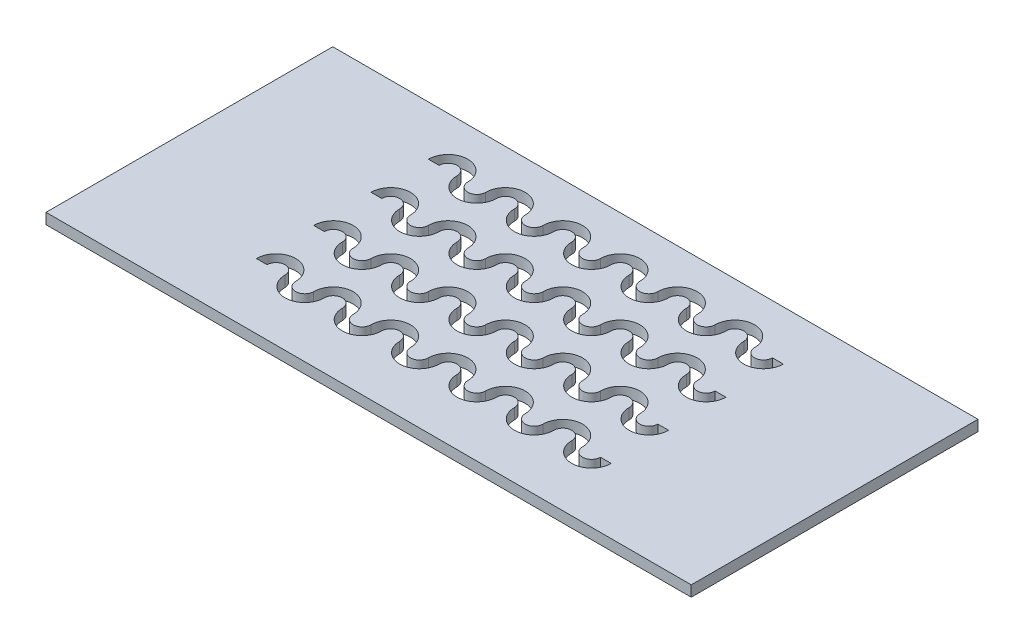
from build123d import *

# Parameters (mm, degrees)
SKETCH1_W               = 180
SKETCH1_H               = 80
BOSS_EXTRUDE1_DEPTH     = 3
CUT_EXTRUDE_THIN1_DEPTH = 5


with BuildPart() as part:
    # Sketch1 → Boss-Extrude1 (new body)
    with BuildSketch(Plane(origin=(0, 0, 0), x_dir=(1, 0, 0), z_dir=(0, 1, 0))):
        with Locations((90, 40)):
            Rectangle(SKETCH1_W, SKETCH1_H)
    extrude(amount=BOSS_EXTRUDE1_DEPTH)

    # Sketch1_3 → Cut-Extrude-Thin1 (cut, symmetric)
    with BuildSketch(Plane(origin=(0, 0, 0), x_dir=(1, 0, 0), z_dir=(0, 1, 0))):
        with BuildLine():
            ThreePointArc((136.5, 66.174335789), (134, 63.674335789), (131.5, 66.174335789))
            ThreePointArc((131.5, 66.174335789), (126, 71.674335789), (120.5, 66.174335789))
            ThreePointArc((120.5, 66.174335789), (118, 63.674335789), (115.5, 66.174335789))
            ThreePointArc((115.5, 66.174335789), (110, 71.674335789), (104.5, 66.174335789))
            ThreePointArc((104.5, 66.174335789), (102, 63.674335789), (99.5, 66.174335789))
            ThreePointArc((99.5, 66.174335789), (94, 71.674335789), (88.5, 66.174335789))
            ThreePointArc((88.5, 66.174335789), (86, 63.674335789), (83.5, 66.174335789))
            ThreePointArc((83.5, 66.174335789), (78, 71.674335789), (72.5, 66.174335789))
            ThreePointArc((72.5, 66.174335789), (70, 63.674335789), (67.5, 66.174335789))
            ThreePointArc((67.5, 66.174335789), (62, 71.674335789), (56.5, 66.174335789))
            ThreePointArc((56.5, 66.174335789), (54, 63.674335789), (51.5, 66.174335789))
            ThreePointArc((51.5, 66.174335789), (46, 71.674335789), (40.5, 66.174335789))
            Line((40.5, 66.174335789), (43.5, 66.174335789))
            ThreePointArc((43.5, 66.174335789), (46, 68.674335789), (48.5, 66.174335789))
            ThreePointArc((48.5, 66.174335789), (54, 60.674335789), (59.5, 66.174335789))
            ThreePointArc((59.5, 66.174335789), (62, 68.674335789), (64.5, 66.174335789))
            ThreePointArc((64.5, 66.174335789), (70, 60.674335789), (75.5, 66.174335789))
            ThreePointArc((75.5, 66.174335789), (78, 68.674335789), (80.5, 66.174335789))
            ThreePointArc((80.5, 66.174335789), (86, 60.674335789), (91.5, 66.174335789))
            ThreePointArc((91.5, 66.174335789), (94, 68.674335789), (96.5, 66.174335789))
            ThreePointArc((96.5, 66.174335789), (102, 60.674335789), (107.5, 66.174335789))
            ThreePointArc((107.5, 66.174335789), (110, 68.674335789), (112.5, 66.174335789))
            ThreePointArc((112.5, 66.174335789), (118, 60.674335789), (123.5, 66.174335789))
            ThreePointArc((123.5, 66.174335789), (126, 68.674335789), (128.5, 66.174335789))
            ThreePointArc((128.5, 66.174335789), (134, 60.674335789), (139.5, 66.174335789))
            Line((139.5, 66.174335789), (136.5, 66.174335789))
        make_face()
        with BuildLine():
            ThreePointArc((136.5, 50.174335789), (134, 47.674335789), (131.5, 50.174335789))
            ThreePointArc((131.5, 50.174335789), (126, 55.674335789), (120.5, 50.174335789))
            ThreePointArc((120.5, 50.174335789), (118, 47.674335789), (115.5, 50.174335789))
            ThreePointArc((115.5, 50.174335789), (110, 55.674335789), (104.5, 50.174335789))
            ThreePointArc((104.5, 50.174335789), (102, 47.674335789), (99.5, 50.174335789))
            ThreePointArc((99.5, 50.174335789), (94, 55.674335789), (88.5, 50.174335789))
            ThreePointArc((88.5, 50.174335789), (86, 47.674335789), (83.5, 50.174335789))
            ThreePointArc((83.5, 50.174335789), (78, 55.674335789), (72.5, 50.174335789))
            ThreePointArc((72.5, 50.174335789), (70, 47.674335789), (67.5, 50.174335789))
            ThreePointArc((67.5, 50.174335789), (62, 55.674335789), (56.5, 50.174335789))
            ThreePointArc((56.5, 50.174335789), (54, 47.674335789), (51.5, 50.174335789))
            ThreePointArc((51.5, 50.174335789), (46, 55.674335789), (40.5, 50.174335789))
            Line((40.5, 50.174335789), (43.5, 50.174335789))
            ThreePointArc((43.5, 50.174335789), (46, 52.674335789), (48.5, 50.174335789))
            ThreePointArc((48.5, 50.174335789), (54, 44.674335789), (59.5, 50.174335789))
            ThreePointArc((59.5, 50.174335789), (62, 52.674335789), (64.5, 50.174335789))
            ThreePointArc((64.5, 50.174335789), (70, 44.674335789), (75.5, 50.174335789))
            ThreePointArc((75.5, 50.174335789), (78, 52.674335789), (80.5, 50.174335789))
            ThreePointArc((80.5, 50.174335789), (86, 44.674335789), (91.5, 50.174335789))
            ThreePointArc((91.5, 50.174335789), (94, 52.674335789), (96.5, 50.174335789))
            ThreePointArc((96.5, 50.174335789), (102, 44.674335789), (107.5, 50.174335789))
            ThreePointArc((107.5, 50.174335789), (110, 52.674335789), (112.5, 50.174335789))
            ThreePointArc((112.5, 50.174335789), (118, 44.674335789), (123.5, 50.174335789))
            ThreePointArc((123.5, 50.174335789), (126, 52.674335789), (128.5, 50.174335789))
            ThreePointArc((128.5, 50.174335789), (134, 44.674335789), (139.5, 50.174335789))
            Line((139.5, 50.174335789), (136.5, 50.174335789))
        make_face()
        with BuildLine():
            ThreePointArc((136.5, 34.174335789), (134, 31.674335789), (131.5, 34.174335789))
            ThreePointArc((131.5, 34.174335789), (126, 39.674335789), (120.5, 34.174335789))
            ThreePointArc((120.5, 34.174335789), (118, 31.674335789), (115.5, 34.174335789))
            ThreePointArc((115.5, 34.174335789), (110, 39.674335789), (104.5, 34.174335789))
            ThreePointArc((104.5, 34.174335789), (102, 31.674335789), (99.5, 34.174335789))
            ThreePointArc((99.5, 34.174335789), (94, 39.674335789), (88.5, 34.174335789))
            ThreePointArc((88.5, 34.174335789), (86, 31.674335789), (83.5, 34.174335789))
            ThreePointArc((83.5, 34.174335789), (78, 39.674335789), (72.5, 34.174335789))
            ThreePointArc((72.5, 34.174335789), (70, 31.674335789), (67.5, 34.174335789))
            ThreePointArc((67.5, 34.174335789), (62, 39.674335789), (56.5, 34.174335789))
            ThreePointArc((56.5, 34.174335789), (54, 31.674335789), (51.5, 34.174335789))
            ThreePointArc((51.5, 34.174335789), (46, 39.674335789), (40.5, 34.174335789))
            Line((40.5, 34.174335789), (43.5, 34.174335789))
            ThreePointArc((43.5, 34.174335789), (46, 36.674335789), (48.5, 34.174335789))
            ThreePointArc((48.5, 34.174335789), (54, 28.674335789), (59.5, 34.174335789))
            ThreePointArc((59.5, 34.174335789), (62, 36.674335789), (64.5, 34.174335789))
            ThreePointArc((64.5, 34.174335789), (70, 28.674335789), (75.5, 34.174335789))
            ThreePointArc((75.5, 34.174335789), (78, 36.674335789), (80.5, 34.174335789))
            ThreePointArc((80.5, 34.174335789), (86, 28.674335789), (91.5, 34.174335789))
            ThreePointArc((91.5, 34.174335789), (94, 36.674335789), (96.5, 34.174335789))
            ThreePointArc((96.5, 34.174335789), (102, 28.674335789), (107.5, 34.174335789))
            ThreePointArc((107.5, 34.174335789), (110, 36.674335789), (112.5, 34.174335789))
            ThreePointArc((112.5, 34.174335789), (118, 28.674335789), (123.5, 34.174335789))
            ThreePointArc((123.5, 34.174335789), (126, 36.674335789), (128.5, 34.174335789))
            ThreePointArc((128.5, 34.174335789), (134, 28.674335789), (139.5, 34.174335789))
            Line((139.5, 34.174335789), (136.5, 34.174335789))
        make_face()
        with BuildLine():
            ThreePointArc((136.5, 18.174335789), (134, 15.674335789), (131.5, 18.174335789))
            ThreePointArc((131.5, 18.174335789), (126, 23.674335789), (120.5, 18.174335789))
            ThreePointArc((120.5, 18.174335789), (118, 15.674335789), (115.5, 18.174335789))
            ThreePointArc((115.5, 18.174335789), (110, 23.674335789), (104.5, 18.174335789))
            ThreePointArc((104.5, 18.174335789), (102, 15.674335789), (99.5, 18.174335789))
            ThreePointArc((99.5, 18.174335789), (94, 23.674335789), (88.5, 18.174335789))
            ThreePointArc((88.5, 18.174335789), (86, 15.674335789), (83.5, 18.174335789))
            ThreePointArc((83.5, 18.174335789), (78, 23.674335789), (72.5, 18.174335789))
            ThreePointArc((72.5, 18.174335789), (70, 15.674335789), (67.5, 18.174335789))
            ThreePointArc((67.5, 18.174335789), (62, 23.674335789), (56.5, 18.174335789))
            ThreePointArc((56.5, 18.174335789), (54, 15.674335789), (51.5, 18.174335789))
            ThreePointArc((51.5, 18.174335789), (46, 23.674335789), (40.5, 18.174335789))
            Line((40.5, 18.174335789), (43.5, 18.174335789))
            ThreePointArc((43.5, 18.174335789), (46, 20.674335789), (48.5, 18.174335789))
            ThreePointArc((48.5, 18.174335789), (54, 12.674335789), (59.5, 18.174335789))
            ThreePointArc((59.5, 18.174335789), (62, 20.674335789), (64.5, 18.174335789))
            ThreePointArc((64.5, 18.174335789), (70, 12.674335789), (75.5, 18.174335789))
            ThreePointArc((75.5, 18.174335789), (78, 20.674335789), (80.5, 18.174335789))
            ThreePointArc((80.5, 18.174335789), (86, 12.674335789), (91.5, 18.174335789))
            ThreePointArc((91.5, 18.174335789), (94, 20.674335789), (96.5, 18.174335789))
            ThreePointArc((96.5, 18.174335789), (102, 12.674335789), (107.5, 18.174335789))
            ThreePointArc((107.5, 18.174335789), (110, 20.674335789), (112.5, 18.174335789))
            ThreePointArc((112.5, 18.174335789), (118, 12.674335789), (123.5, 18.174335789))
            ThreePointArc((123.5, 18.174335789), (126, 20.674335789), (128.5, 18.174335789))
            ThreePointArc((128.5, 18.174335789), (134, 12.674335789), (139.5, 18.174335789))
            Line((139.5, 18.174335789), (136.5, 18.174335789))
        make_face()
    extrude(amount=CUT_EXTRUDE_THIN1_DEPTH, both=True, mode=Mode.SUBTRACT)


solid = part.part
